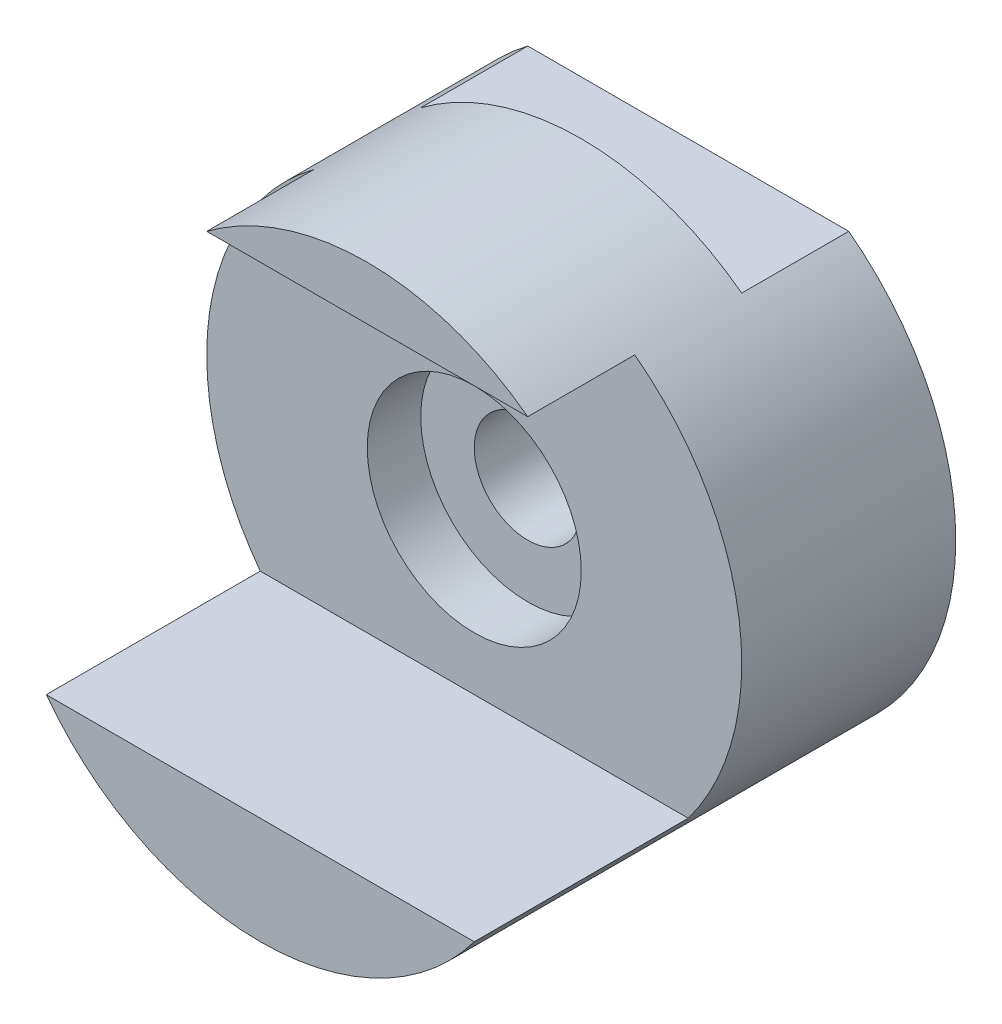
from build123d import *

# Parameters (mm, degrees)
SKETCH1_R           = 5
SKETCH1_R_2         = 1
BOSS_EXTRUDE1_DEPTH = 8
SKETCH2_W           = 2
SKETCH2_H           = 1
CUT_EXTRUDE1_DEPTH  = 9
SKETCH3_R           = 2
CUT_EXTRUDE2_DEPTH  = 1


with BuildPart() as part:
    # Sketch1 → Boss-Extrude1 (new body)
    with BuildSketch(Plane.XY):
        Circle(SKETCH1_R)
        Circle(SKETCH1_R_2, mode=Mode.SUBTRACT)
    extrude(amount=BOSS_EXTRUDE1_DEPTH)

    # Sketch2 → Cut-Extrude1 (cut, symmetric)
    with BuildSketch(Plane(origin=(0, 0, 0), x_dir=(0, 0, -1), z_dir=(1, 0, 0))):
        Polygon((-8, -3), (-4, -3), (-4, 4), (-6, 4), (-6, 5), (-8, 5), align=None)
        with Locations((-1, 4.5)):
            Rectangle(SKETCH2_W, SKETCH2_H)
    extrude(amount=CUT_EXTRUDE1_DEPTH, both=True, mode=Mode.SUBTRACT)

    # Sketch3 → Cut-Extrude2 (cut)
    with BuildSketch(Plane.XY.offset(4)):
        Circle(SKETCH3_R)
    extrude(amount=-CUT_EXTRUDE2_DEPTH, mode=Mode.SUBTRACT)


solid = part.part
